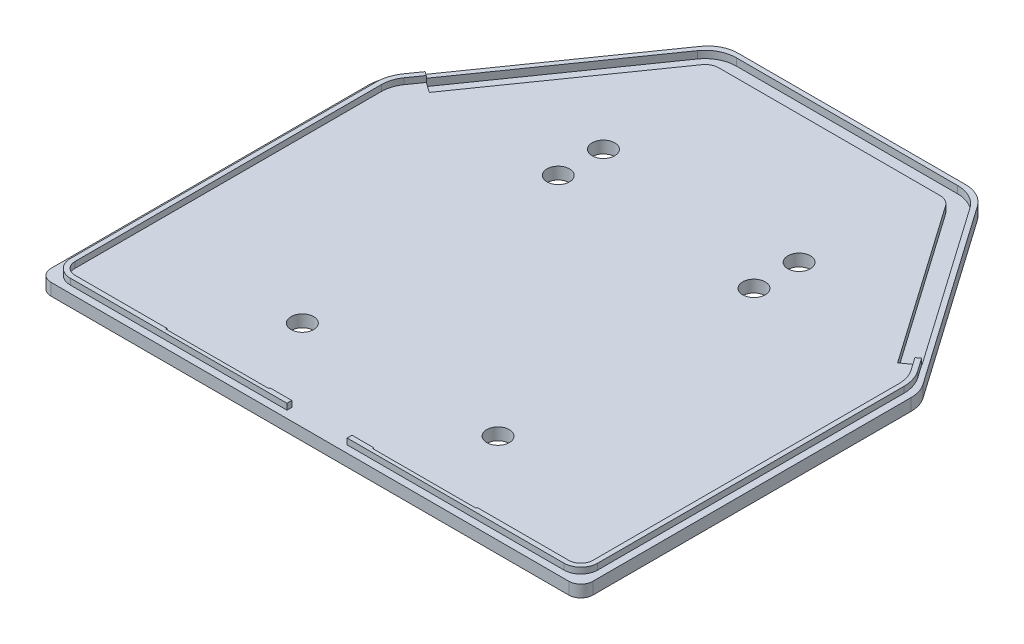
from build123d import *

# Parameters (mm, degrees)
SKETCH2_W               = 114.3
SKETCH2_H               = 101.6
BOSS_EXTRUDE1_DEPTH     = 2.54
SKETCH3_W               = 19.05
SKETCH3_H               = 38.1
BOSS_EXTRUDE2_DEPTH     = 2.54
TRUCKMOUNTINGHOLES_R    = 2.38125
CUT_EXTRUDE1_DEPTH      = 6.08
FILLET1_R               = 2.54
CUT_EXTRUDE3_DEPTH      = 3.54
CUT_EXTRUDE3_DEPTH_BACK = 3.54
BOSS_EXTRUDE3_DEPTH     = 2.54
CUT_EXTRUDE4_DEPTH      = 1.524
FILLET2_R               = 6.35
SKETCH8_W               = 22.225
SKETCH8_H               = 2.54
BOSS_EXTRUDE4_DEPTH     = 2.54
CUT_EXTRUDE5_DEPTH      = 2.54
SKETCH10_W              = 60.325
SKETCH10_H              = 101.6
CUT_EXTRUDE6_DEPTH      = 2.54
BOSS_EXTRUDE5_DEPTH     = 1.27


with BuildPart() as part:
    # Sketch2 → Boss-Extrude1 (new body)
    with BuildSketch(Plane(origin=(0, 0, 0), x_dir=(1, 0, 0), z_dir=(0, 1, 0))):
        Rectangle(SKETCH2_W, SKETCH2_H)
    extrude(amount=BOSS_EXTRUDE1_DEPTH)

    # Sketch3 → Boss-Extrude2 (add)
    with BuildSketch(Plane(origin=(0, 2.54, 0), x_dir=(1, 0, 0), z_dir=(0, 1, 0))):
        with Locations((-20.6375, -31.75)):
            Rectangle(SKETCH3_W, SKETCH3_H)
        with Locations((20.6375, -31.75)):
            Rectangle(SKETCH3_W, SKETCH3_H)
        Polygon((-30.1625, 41.705647627), (-30.1625, 12.7), (-11.1125, 12.7), (-11.1125, 50.8), (-23.794565913, 50.8), align=None)
        Polygon((11.1125, 50.8), (11.1125, 12.7), (30.1625, 12.7), (30.1625, 41.705647627), (23.794565913, 50.8), align=None)
    extrude(amount=BOSS_EXTRUDE2_DEPTH)

    # TruckMountingHoles → Cut-Extrude1 (cut, through all)
    with BuildSketch(Plane(origin=(0, 0, 0), x_dir=(1, 0, 0), z_dir=(0, 1, 0))):
        with Locations((-20.6375, 22.225)):
            Circle(TRUCKMOUNTINGHOLES_R)
        with Locations((-20.6375, 31.75)):
            Circle(TRUCKMOUNTINGHOLES_R)
        with Locations((20.6375, 31.75)):
            Circle(TRUCKMOUNTINGHOLES_R)
        with Locations((20.6375, 22.225)):
            Circle(TRUCKMOUNTINGHOLES_R)
        with Locations((20.6375, -31.75)):
            Circle(TRUCKMOUNTINGHOLES_R)
        with Locations((-20.6375, -31.75)):
            Circle(TRUCKMOUNTINGHOLES_R)
    extrude(amount=CUT_EXTRUDE1_DEPTH, mode=Mode.SUBTRACT)

    # Fillet1
    fillet1_edges = [part.edges().sort_by_distance(p)[0] for p in [
        (57.15, 1.27, 50.8),
        (-57.15, 1.27, 50.8),
        (-57.15, 1.27, -50.8),
        (57.15, 1.27, -50.8),
    ]]
    fillet(fillet1_edges, radius=FILLET1_R)

    # Sketch5 → Cut-Extrude3 (cut, two sides)
    with BuildSketch(Plane(origin=(0, 2.54, 0), x_dir=(1, 0, 0), z_dir=(0, 1, 0))) as cut_extrude3_sk:
        with BuildLine():
            Line((54.61, 50.8), (36.197635735, 50.8))
            Line((36.197635735, 50.8), (57.15, 20.876922739))
            Line((57.15, 20.876922739), (57.15, 48.26))
            ThreePointArc((57.15, 48.26), (56.406051224, 50.056051224), (54.61, 50.8))
        make_face()
        with BuildLine():
            Line((-57.15, 20.876922739), (-36.197635735, 50.8))
            Line((-36.197635735, 50.8), (-54.61, 50.8))
            ThreePointArc((-54.61, 50.8), (-56.406051224, 50.056051224), (-57.15, 48.26))
            Line((-57.15, 48.26), (-57.15, 20.876922739))
        make_face()
    extrude(amount=CUT_EXTRUDE3_DEPTH, mode=Mode.SUBTRACT)
    extrude(cut_extrude3_sk.sketch, amount=-CUT_EXTRUDE3_DEPTH_BACK, mode=Mode.SUBTRACT)

    # Sketch5_5 → Boss-Extrude3 (add)
    with BuildSketch(Plane(origin=(0, 2.54, 0), x_dir=(1, 0, 0), z_dir=(0, 1, 0))):
        Polygon((36.197635735, 50.8), (27.305, 63.5), (-27.305, 63.5), (-36.197635735, 50.8), (-25.500724295, 50.8), (-23.794565913, 50.8), (-11.1125, 50.8), (11.1125, 50.8), (23.794565913, 50.8), align=None)
    extrude(amount=-BOSS_EXTRUDE3_DEPTH)

    # Sketch6 → Cut-Extrude4 (cut)
    with BuildSketch(Plane(origin=(0, 2.54, 0), x_dir=(1, 0, 0), z_dir=(0, 1, 0))):
        with BuildLine():
            Line((49.383451528, 23.776246966), (52.400388507, 25.888728981))
            Line((52.400388507, 25.888728981), (28.747959175, 59.667898786))
            ThreePointArc((28.747959175, 59.667898786), (26.387666917, 61.737819542), (23.338279075, 62.484))
            Line((23.338279075, 62.484), (-23.338279075, 62.484))
            ThreePointArc((-23.338279075, 62.484), (-26.387666917, 61.737819542), (-28.747959175, 59.667898786))
            Line((-28.747959175, 59.667898786), (-52.400388507, 25.888728981))
            Line((-52.400388507, 25.888728981), (-49.383451528, 23.776246966))
            Line((-49.383451528, 23.776246966), (-25.731022196, 57.555416771))
            ThreePointArc((-25.731022196, 57.555416771), (-24.687046774, 58.470958644), (-23.338279075, 58.801))
            Line((-23.338279075, 58.801), (23.338279075, 58.801))
            ThreePointArc((23.338279075, 58.801), (24.687046774, 58.470958644), (25.731022196, 57.555416771))
            Line((25.731022196, 57.555416771), (49.383451528, 23.776246966))
        make_face()
    extrude(amount=-CUT_EXTRUDE4_DEPTH, mode=Mode.SUBTRACT)

    # Fillet2
    fillet2_edges = [part.edges().sort_by_distance(p)[0] for p in [
        (57.15, 1.27, -20.876922739),
        (-57.15, 1.27, -20.876922739),
        (-27.305, 1.27, -63.5),
        (27.305, 1.27, -63.5),
    ]]
    fillet(fillet2_edges, radius=FILLET2_R)

    # Sketch8 → Boss-Extrude4 (add)
    with BuildSketch(Plane(origin=(0, 2.54, 0), x_dir=(1, 0, 0), z_dir=(0, 1, 0))):
        with Locations((0, -49.53)):
            Rectangle(SKETCH8_W, SKETCH8_H)
    extrude(amount=BOSS_EXTRUDE4_DEPTH)

    # Sketch9 → Cut-Extrude5 (cut)
    with BuildSketch(Plane.XY.offset(50.8)):
        with BuildLine():
            Line((6.346056871, 5.08), (-6.346056871, 5.08))
            ThreePointArc((-6.346056871, 5.08), (-5.941945474, 4.247288898), (-5.08, 3.91))
            Line((-5.08, 3.91), (5.08, 3.91))
            ThreePointArc((5.08, 3.91), (5.941945474, 4.247288898), (6.346056871, 5.08))
        make_face()
    extrude(amount=-CUT_EXTRUDE5_DEPTH, mode=Mode.SUBTRACT)

    # Sketch10 → Cut-Extrude6 (cut)
    with BuildSketch(Plane(origin=(0, 5.08, 0), x_dir=(1, 0, 0), z_dir=(0, 1, 0))):
        Rectangle(SKETCH10_W, SKETCH10_H)
    extrude(amount=-CUT_EXTRUDE6_DEPTH, mode=Mode.SUBTRACT)

    # Sketch11 → Boss-Extrude5 (add)
    with BuildSketch(Plane(origin=(0, 2.54, 0), x_dir=(1, 0, 0), z_dir=(0, 1, 0))):
        with BuildLine():
            add(Edge.make_bspline(
                [(52.064454926, -49.276), (52.527212299, -49.276), (53.462925017, -49.090999134), (54.645555287, -48.299984177), (55.437822336, -47.118247374), (55.623227463, -46.182681141), (55.623227463, -45.72)],
                knots=[3.141592654, 3.141592654, 3.141592654, 3.141592654, 3.534291735, 3.926990817, 4.319689899, 4.71238898, 4.71238898, 4.71238898, 4.71238898], degree=3))
            Line((55.623227463, -45.72), (55.623227463, -44.409940581))
            add(Edge.make_bspline(
                [(55.623227463, -44.409940581), (55.455682863, -44.009381364), (55.203452495, -43.645913792), (54.861227463, -43.351588173)],
                knots=[5.070956634, 5.070956634, 5.070956634, 5.070956634, 5.421823055, 5.421823055, 5.421823055, 5.421823055], degree=3))
            Line((54.861227463, -43.351588173), (54.861227463, -45.72))
            add(Edge.make_bspline(
                [(54.861227463, -45.72), (54.861227463, -46.432957974), (54.264419916, -47.918029594), (52.777827726, -48.514), (52.064454926, -48.514)],
                knots=[1.570796327, 1.570796327, 1.570796327, 1.570796327, 2.35619449, 3.141592654, 3.141592654, 3.141592654, 3.141592654], degree=3))
            Line((52.064454926, -48.514), (49.69227773, -48.514))
            add(Edge.make_bspline(
                [(49.69227773, -48.514), (49.98720822, -48.856186046), (50.351337017, -49.108435697), (50.752582292, -49.276)],
                knots=[2.431141263, 2.431141263, 2.431141263, 2.431141263, 2.78255448, 2.78255448, 2.78255448, 2.78255448], degree=3))
            Line((50.752582292, -49.276), (52.064454926, -49.276))
        make_face()
        with BuildLine():
            add(Edge.make_bspline(
                [(55.623227463, -44.409940581), (55.455682863, -44.009381364), (55.203452495, -43.645913792), (54.861227463, -43.351588173)],
                knots=[5.070956634, 5.070956634, 5.070956634, 5.070956634, 5.421823055, 5.421823055, 5.421823055, 5.421823055], degree=3))
            Line((55.623227463, -44.409940581), (55.623227463, -34.698805774))
            Line((55.623227463, -34.698805774), (55.623227463, 17.084765836))
            add(Edge.make_bspline(
                [(54.861227463, 15.559588906), (55.205040884, 16.01706212), (55.456487689, 16.533521145), (55.623227463, 17.084765836)],
                knots=[-0.795165299, -0.795165299, -0.795165299, -0.795165299, -0.40392164, -0.40392164, -0.40392164, -0.40392164], degree=3))
            Line((54.861227463, 15.559588906), (54.861227463, -35.534958582))
            Line((54.861227463, -35.534958582), (54.861227463, -43.351588173))
        make_face()
        with BuildLine():
            Line((54.607227463, -35.821330198), (54.607227463, -43.157480027))
            add(Edge.make_bspline(
                [(54.861227463, -43.351588173), (54.781471113, -43.282994893), (54.696826846, -43.218156948), (54.607227463, -43.157480027)],
                knots=[5.421823055, 5.421823055, 5.421823055, 5.421823055, 5.503593302, 5.503593302, 5.503593302, 5.503593302], degree=3))
            Line((54.861227463, -43.351588173), (54.861227463, -35.534958582))
            Line((54.861227463, -35.534958582), (54.861227463, 15.559588906))
            add(Edge.make_bspline(
                [(54.607227463, 15.251351548), (54.69691799, 15.350728874), (54.781552882, 15.453575049), (54.861227463, 15.559588906)],
                knots=[-0.885831261, -0.885831261, -0.885831261, -0.885831261, -0.795165299, -0.795165299, -0.795165299, -0.795165299], degree=3))
            Line((54.607227463, 15.251351548), (54.607227463, -35.821330198))
        make_face()
        with BuildLine():
            add(Edge.make_bspline(
                [(54.861227463, -43.351588173), (54.781471113, -43.282994893), (54.696826846, -43.218156948), (54.607227463, -43.157480027)],
                knots=[5.421823055, 5.421823055, 5.421823055, 5.421823055, 5.503593302, 5.503593302, 5.503593302, 5.503593302], degree=3))
            Line((54.607227463, -43.157480027), (54.607227463, -45.72))
            add(Edge.make_bspline(
                [(52.064454926, -48.26), (54.607227463, -48.26), (54.607227463, -45.72)],
                knots=[1.570796327, 1.570796327, 1.570796327, 3.141592654, 3.141592654, 3.141592654], degree=2, weights=[1, 0.707106781, 1]))
            Line((52.064454926, -48.26), (49.497730822, -48.26))
            add(Edge.make_bspline(
                [(49.497730822, -48.26), (49.558549509, -48.349597111), (49.623533898, -48.434241613), (49.69227773, -48.514)],
                knots=[2.349232162, 2.349232162, 2.349232162, 2.349232162, 2.431141263, 2.431141263, 2.431141263, 2.431141263], degree=3))
            Line((49.69227773, -48.514), (52.064454926, -48.514))
            add(Edge.make_bspline(
                [(54.861227463, -45.72), (54.861227463, -46.432957974), (54.264419916, -47.918029594), (52.777827726, -48.514), (52.064454926, -48.514)],
                knots=[1.570796327, 1.570796327, 1.570796327, 1.570796327, 2.35619449, 3.141592654, 3.141592654, 3.141592654, 3.141592654], degree=3))
            Line((54.861227463, -45.72), (54.861227463, -43.351588173))
        make_face()
        with BuildLine():
            Line((41.039104509, -49.276), (50.752582292, -49.276))
            add(Edge.make_bspline(
                [(49.69227773, -48.514), (49.98720822, -48.856186046), (50.351337017, -49.108435697), (50.752582292, -49.276)],
                knots=[2.431141263, 2.431141263, 2.431141263, 2.431141263, 2.78255448, 2.78255448, 2.78255448, 2.78255448], degree=3))
            Line((49.69227773, -48.514), (41.877400806, -48.514))
            Line((41.877400806, -48.514), (32.7025, -48.514))
            Line((32.7025, -48.514), (27.86827623, -48.514))
            add(Edge.make_bspline(
                [(27.86827623, -48.514), (27.846578806, -48.767183697), (27.82498302, -49.021182908), (27.803489623, -49.276)],
                knots=[6.367915657, 6.367915657, 6.367915657, 6.367915657, 6.385943787, 6.385943787, 6.385943787, 6.385943787], degree=3))
            Line((27.803489623, -49.276), (32.7025, -49.276))
            Line((32.7025, -49.276), (41.039104509, -49.276))
        make_face()
        with BuildLine():
            add(Edge.make_bspline(
                [(54.861227463, 15.559588906), (55.205040884, 16.01706212), (55.456487689, 16.533521145), (55.623227463, 17.084765836)],
                knots=[-0.795165299, -0.795165299, -0.795165299, -0.795165299, -0.40392164, -0.40392164, -0.40392164, -0.40392164], degree=3))
            Line((55.623227463, 17.084765836), (55.623227463, 18.876688069))
            add(Edge.make_bspline(
                [(55.623227463, 18.876688069), (55.623227463, 20.352383987), (55.138231725, 21.889973031), (54.29188787, 23.098848758)],
                knots=[0, 0, 0, 0, 1, 1, 1, 1], degree=3))
            Line((54.29188787, 23.098848758), (53.263692187, 24.567472646))
            add(Edge.make_bspline(
                [(53.263692187, 24.567472646), (52.876307698, 24.87211251), (52.452799222, 25.12030497), (51.997969643, 25.296875514)],
                knots=[1.404144693, 1.404144693, 1.404144693, 1.404144693, 1.739017276, 1.739017276, 1.739017276, 1.739017276], degree=3))
            Line((51.997969643, 25.296875514), (51.880453354, 25.214589722))
            Line((51.880453354, 25.214589722), (53.66766489, 22.661825108))
            add(Edge.make_bspline(
                [(53.66766489, 22.661825108), (54.426407639, 21.578074471), (54.861227463, 20.199641583), (54.861227463, 18.876688069)],
                knots=[0, 0, 0, 0, 1, 1, 1, 1], degree=3))
            Line((54.861227463, 18.876688069), (54.861227463, 15.559588906))
        make_face()
        with BuildLine():
            Line((41.877400806, -48.514), (49.69227773, -48.514))
            add(Edge.make_bspline(
                [(49.497730822, -48.26), (49.558549509, -48.349597111), (49.623533898, -48.434241613), (49.69227773, -48.514)],
                knots=[2.349232162, 2.349232162, 2.349232162, 2.349232162, 2.431141263, 2.431141263, 2.431141263, 2.431141263], degree=3))
            Line((49.497730822, -48.26), (42.164507917, -48.26))
            Line((42.164507917, -48.26), (32.7025, -48.26))
            Line((32.7025, -48.26), (32.7025, -48.514))
            Line((32.7025, -48.514), (41.877400806, -48.514))
        make_face()
        with BuildLine():
            add(Edge.make_bspline(
                [(54.607227463, 15.251351548), (54.69691799, 15.350728874), (54.781552882, 15.453575049), (54.861227463, 15.559588906)],
                knots=[-0.885831261, -0.885831261, -0.885831261, -0.885831261, -0.795165299, -0.795165299, -0.795165299, -0.795165299], degree=3))
            Line((54.861227463, 15.559588906), (54.861227463, 18.876688069))
            add(Edge.make_bspline(
                [(53.66766489, 22.661825108), (54.426407639, 21.578074471), (54.861227463, 20.199641583), (54.861227463, 18.876688069)],
                knots=[0, 0, 0, 0, 1, 1, 1, 1], degree=3))
            Line((53.66766489, 22.661825108), (51.880453354, 25.214589722))
            Line((51.880453354, 25.214589722), (51.997969643, 25.296875514))
            add(Edge.make_bspline(
                [(51.997969643, 25.296875514), (51.900871398, 25.33457027), (51.802345698, 25.369000867), (51.702439272, 25.400019665)],
                knots=[1.739017276, 1.739017276, 1.739017276, 1.739017276, 1.810506779, 1.810506779, 1.810506779, 1.810506779], degree=3))
            Line((51.702439272, 25.400019665), (51.526714183, 25.276975634))
            Line((51.526714183, 25.276975634), (53.459590563, 22.516150558))
            add(Edge.make_bspline(
                [(53.459590563, 22.516150558), (53.833000013, 21.982790957), (54.11786933, 21.405096809), (54.50929647, 20.163665719), (54.607227463, 19.527775664), (54.607227463, 18.876688069)],
                knots=[0, 0, 0, 0, 0.5, 0.5, 1, 1, 1, 1], degree=3))
            Line((54.607227463, 18.876688069), (54.607227463, 15.251351548))
        make_face()
        with BuildLine():
            Line((6.604, -49.276), (27.803489623, -49.276))
            add(Edge.make_bspline(
                [(27.86827623, -48.514), (27.846578806, -48.767183697), (27.82498302, -49.021182908), (27.803489623, -49.276)],
                knots=[6.367915657, 6.367915657, 6.367915657, 6.367915657, 6.385943787, 6.385943787, 6.385943787, 6.385943787], degree=3))
            Line((27.86827623, -48.514), (10.922, -48.514))
            Line((10.922, -48.514), (6.604, -48.514))
            Line((6.604, -48.514), (6.604, -49.276))
        make_face()
        with BuildLine():
            add(Edge.make_bspline(
                [(53.263692187, 24.567472646), (52.876307698, 24.87211251), (52.452799222, 25.12030497), (51.997969643, 25.296875514)],
                knots=[1.404144693, 1.404144693, 1.404144693, 1.404144693, 1.739017276, 1.739017276, 1.739017276, 1.739017276], degree=3))
            Line((53.263692187, 24.567472646), (52.504647213, 25.651654967))
            Line((52.504647213, 25.651654967), (51.997969643, 25.296875514))
        make_face()
        Polygon((6.35, -49.276), (6.604, -49.276), (6.604, -48.514), (10.922, -48.514), (10.922, -48.26), (6.35, -48.26), align=None)
        with BuildLine():
            Line((51.997969643, 25.296875514), (52.504647213, 25.651654967))
            Line((52.504647213, 25.651654967), (52.358958798, 25.859719586))
            Line((52.358958798, 25.859719586), (51.702439272, 25.400019665))
            add(Edge.make_bspline(
                [(51.997969643, 25.296875514), (51.900871398, 25.33457027), (51.802345698, 25.369000867), (51.702439272, 25.400019665)],
                knots=[1.739017276, 1.739017276, 1.739017276, 1.739017276, 1.810506779, 1.810506779, 1.810506779, 1.810506779], degree=3))
        make_face()
    boss_extrude5 = extrude(amount=BOSS_EXTRUDE5_DEPTH)

    # Mirror1: Boss-Extrude5 across plane
    add(boss_extrude5.mirror(Plane(origin=(0, 0, 0), x_dir=(0, 0, 1), z_dir=(1, 0, 0))))


solid = part.part
